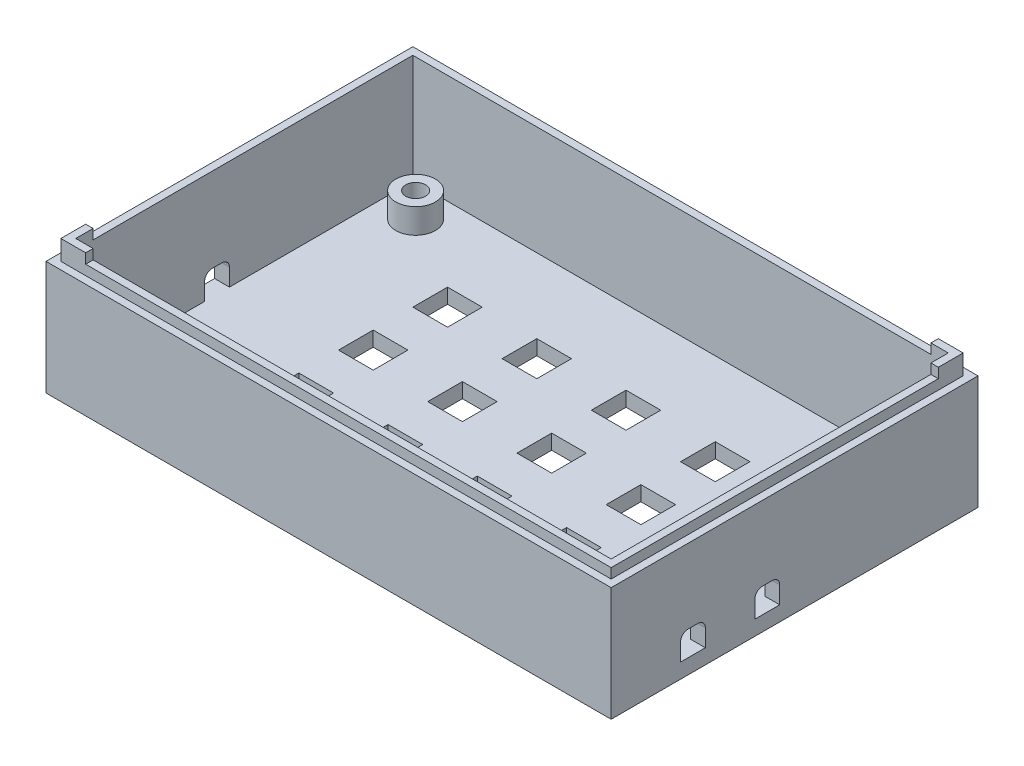
from build123d import *

# Parameters (mm, degrees)
SKETCH1_W                = 108
SKETCH1_H                = 68
SKETCH1_R                = 2
BOSS_EXTRUDE1_DEPTH      = 3
SKETCH2_W                = 114
SKETCH2_H                = 74
SKETCH2_W_2              = 108
SKETCH2_H_2              = 68
BOSS_EXTRUDE2_DEPTH      = 20
BOSS_EXTRUDE2_DEPTH_BACK = 3
SKETCH4_W                = 111
SKETCH4_H                = 71
SKETCH4_W_2              = 108
SKETCH4_H_2              = 68
BOSS_EXTRUDE3_DEPTH      = 2
CUT_EXTRUDE1_DEPTH       = 4
SKETCH6_R                = 4
SKETCH6_R_2              = 2
BOSS_EXTRUDE4_DEPTH      = 5
SKETCH7_W                = 7
SKETCH7_H                = 7
CUT_EXTRUDE2_DEPTH       = 4
BOSS_EXTRUDE5_DEPTH      = 2


with BuildPart() as part:
    # Sketch1 → Boss-Extrude1 (new body)
    with BuildSketch(Plane(origin=(0, 0, 0), x_dir=(1, 0, 0), z_dir=(0, 1, 0))):
        Rectangle(SKETCH1_W, SKETCH1_H)
        with Locations((-47.1, 27.655555556)):
            Circle(SKETCH1_R, mode=Mode.SUBTRACT)
        with Locations((47.1, 27.655555556)):
            Circle(SKETCH1_R, mode=Mode.SUBTRACT)
        with Locations((47.1, -27.655555556)):
            Circle(SKETCH1_R, mode=Mode.SUBTRACT)
        with Locations((-47.1, -27.655555556)):
            Circle(SKETCH1_R, mode=Mode.SUBTRACT)
    extrude(amount=BOSS_EXTRUDE1_DEPTH)

    # Sketch2 → Boss-Extrude2 (add, two sides)
    with BuildSketch(Plane(origin=(0, 3, 0), x_dir=(1, 0, 0), z_dir=(0, 1, 0))) as boss_extrude2_sk:
        Rectangle(SKETCH2_W, SKETCH2_H)
        Rectangle(SKETCH2_W_2, SKETCH2_H_2, mode=Mode.SUBTRACT)
    extrude(amount=BOSS_EXTRUDE2_DEPTH)
    extrude(boss_extrude2_sk.sketch, amount=-BOSS_EXTRUDE2_DEPTH_BACK)

    # Sketch4 → Boss-Extrude3 (add)
    with BuildSketch(Plane(origin=(0, 23, 0), x_dir=(1, 0, 0), z_dir=(0, 1, 0))):
        Rectangle(SKETCH4_W, SKETCH4_H)
        Rectangle(SKETCH4_W_2, SKETCH4_H_2, mode=Mode.SUBTRACT)
    extrude(amount=BOSS_EXTRUDE3_DEPTH)

    # Sketch5 → Cut-Extrude1 (cut, through all)
    with BuildSketch(Plane.ZY.offset(-54)):
        with BuildLine():
            Line((3, 3), (8, 3))
            Line((8, 3), (8, 6.5))
            ThreePointArc((8, 6.5), (7.560660172, 7.560660172), (6.5, 8))
            Line((6.5, 8), (4.5, 8))
            ThreePointArc((4.5, 8), (3.439339828, 7.560660172), (3, 6.5))
            Line((3, 6.5), (3, 3))
        make_face()
        with BuildLine():
            Line((18, 3), (23, 3))
            Line((23, 3), (23, 6.5))
            ThreePointArc((23, 6.5), (22.560660172, 7.560660172), (21.5, 8))
            Line((21.5, 8), (19.5, 8))
            ThreePointArc((19.5, 8), (18.439339828, 7.560660172), (18, 6.5))
            Line((18, 6.5), (18, 3))
        make_face()
    cut_extrude1 = extrude(amount=-CUT_EXTRUDE1_DEPTH, mode=Mode.SUBTRACT)

    # Sketch6 → Boss-Extrude4 (add)
    with BuildSketch(Plane(origin=(0, 3, 0), x_dir=(1, 0, 0), z_dir=(0, 1, 0))):
        with Locations((-47.1, 27.655555556)):
            Circle(SKETCH6_R)
        with Locations((-47.1, 27.655555556)):
            Circle(SKETCH6_R_2, mode=Mode.SUBTRACT)
        with Locations((47.1, 27.655555556)):
            Circle(SKETCH6_R)
        with Locations((47.1, 27.655555556)):
            Circle(SKETCH6_R_2, mode=Mode.SUBTRACT)
        with Locations((47.1, -27.655555556)):
            Circle(SKETCH6_R)
        with Locations((47.1, -27.655555556)):
            Circle(SKETCH6_R_2, mode=Mode.SUBTRACT)
        with Locations((-47.1, -27.655555556)):
            Circle(SKETCH6_R)
        with Locations((-47.1, -27.655555556)):
            Circle(SKETCH6_R_2, mode=Mode.SUBTRACT)
    extrude(amount=BOSS_EXTRUDE4_DEPTH)

    # Sketch7 → Cut-Extrude2 (cut, through all)
    with BuildSketch(Plane(origin=(0, 3, 0), x_dir=(1, 0, 0), z_dir=(0, 1, 0))):
        with Locations((-10.5, 15.5)):
            Rectangle(SKETCH7_W, SKETCH7_H)
        with Locations((-28.5, 15.5)):
            Rectangle(SKETCH7_W, SKETCH7_H)
        with Locations((7.5, 15.5)):
            Rectangle(SKETCH7_W, SKETCH7_H)
        with Locations((25.5, 15.5)):
            Rectangle(SKETCH7_W, SKETCH7_H)
        with Locations((-10.5, 0.5)):
            Rectangle(SKETCH7_W, SKETCH7_H)
        with Locations((7.5, 0.5)):
            Rectangle(SKETCH7_W, SKETCH7_H)
        with Locations((25.5, 0.5)):
            Rectangle(SKETCH7_W, SKETCH7_H)
        with Locations((-10.5, -14.5)):
            Rectangle(SKETCH7_W, SKETCH7_H)
        with Locations((7.5, -14.5)):
            Rectangle(SKETCH7_W, SKETCH7_H)
        with Locations((25.5, -14.5)):
            Rectangle(SKETCH7_W, SKETCH7_H)
        with Locations((-28.5, 0.5)):
            Rectangle(SKETCH7_W, SKETCH7_H)
        with Locations((-28.5, -14.5)):
            Rectangle(SKETCH7_W, SKETCH7_H)
    extrude(amount=-CUT_EXTRUDE2_DEPTH, mode=Mode.SUBTRACT)

    # Mirror1: Cut-Extrude1 across plane
    add(cut_extrude1.mirror(Plane(origin=(0, 0, 0), x_dir=(0, 0, 1), z_dir=(1, 0, 0))), mode=Mode.SUBTRACT)

    # Sketch8 → Boss-Extrude5 (add)
    with BuildSketch(Plane(origin=(0, 25, 0), x_dir=(1, 0, 0), z_dir=(0, 1, 0))):
        Polygon((55.5, 35.5), (50.5, 35.5), (50.5, 34), (54, 34), (54, 30.5), (55.5, 30.5), align=None)
        Polygon((-55.5, -35.5), (-50.5, -35.5), (-50.5, -34), (-54, -34), (-54, -30.5), (-55.5, -30.5), align=None)
    extrude(amount=BOSS_EXTRUDE5_DEPTH)


solid = part.part
